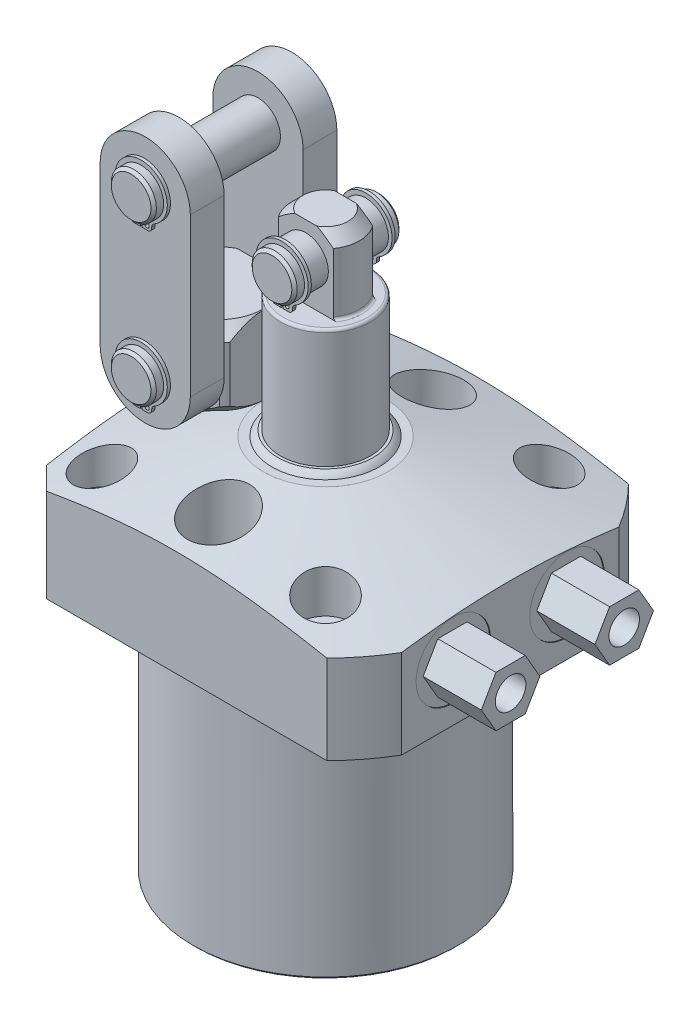
from build123d import *

# Parameters (mm, degrees)
SKETCH3_OUTSIDE_W          = 162.862
SKETCH3_OUTSIDE_H          = 162.862
SKETCH3_OUTSIDE_W_2        = 94.4626
SKETCH3_OUTSIDE_H_2        = 84.9376
CUT_EXTRUDE9_DEPTH         = 106.3498
CHAMFER8_SIZE              = 6.35
CHAMFER5_SIZE              = 0.762
HOLE1_D                    = 8.7376
HOLE1_DEPTH                = 36.4998
HOLE1_CBORE_D              = 14.2748
HOLE1_CBORE_DEPTH          = 17.4498
SKETCH34_R                 = 8.7503
CUT_EXTRUDE10_DEPTH        = 19.05
EXTRUDE14_DEPTH            = 16.383
HOLE2_D                    = 8.6106
HOLE2_DEPTH                = 6.7056
SKETCH33_R                 = 0.889
CUT_EXTRUDE7_DEPTH         = 20.6248
FILLET4_R                  = 0.762
SKETCH29_R                 = 6.3373
EXTRUDE11_DEPTH            = 15.0749
EXTRUDE2_START             = -2.8194
SKETCH16_R                 = 0.5969
EXTRUDE2_DEPTH             = 0.889
CHAMFER6_SIZE              = 0.762
CUT_EXTRUDE11_DEPTH        = 22.225
SKETCH30_R                 = 6.3373
EXTRUDE12_DEPTH            = 24.5999
EXTRUDE4_START             = -2.8194
SKETCH19_R                 = 0.5969
EXTRUDE4_DEPTH             = 0.889
EXTRUDE13_DEPTH            = 9.525
CHAMFER7_SIZE              = 0.762
LPATTERN2_COUNT            = 2
LPATTERN2_PITCH            = 44.45
LPATTERN2_START            = -2.8194
LPATTERN2_COPY_1_SKETCH_R  = 0.5969
LPATTERN2_COPY_1_DEPTH     = 0.889
CHAMFER7_OF_LPATTERN2_SIZE = 0.762


with BuildPart() as part:
    # Sketch28 → Revolve7 (revolve)
    with BuildSketch(Plane.XY, mode=Mode.PRIVATE) as revolve7_sk:
        Polygon((-17.4625, 36.4998), (-60.325, 25.014827739), (-60.325, 0), (-37.2999, 0), (-37.2999, -69.85), (0, -69.85), (0, 36.4998), align=None)
    revolve(revolve7_sk.sketch.rotate(Axis((0, 0, 0), (0, 1, 0)), 270), axis=Axis((0, 0, 0), (0, 1, 0)))  # turned: the seam where the file's is

    # Sketch3 outside → Cut-Extrude9 (cut)
    with BuildSketch(Plane(origin=(0, 36.4998, 0), x_dir=(-1, 0, 0), z_dir=(0, 1, 0))):
        Rectangle(SKETCH3_OUTSIDE_W, SKETCH3_OUTSIDE_H)
        with Locations((-4.7625, 0)):
            Rectangle(SKETCH3_OUTSIDE_W_2, SKETCH3_OUTSIDE_H_2, mode=Mode.SUBTRACT)
    extrude(amount=-CUT_EXTRUDE9_DEPTH, mode=Mode.SUBTRACT)

    # Chamfer8
    chamfer8_edges = [part.edges().sort_by_distance(p)[0] for p in [
        (-42.4688, 12.542923443, -42.4688),
        (-42.4688, 12.542923443, 42.4688),
    ]]
    chamfer(chamfer8_edges, length=CHAMFER8_SIZE)

    # Chamfer5
    chamfer5_edges = [part.edges().sort_by_distance(p)[0] for p in [
        (0, -69.85, 37.2999),
    ]]
    chamfer(chamfer5_edges, length=CHAMFER5_SIZE)

    # Hole1
    with Locations(Plane(origin=(0, 36.4998, 0), x_dir=(-1, 0, 0), z_dir=(0, 1, 0))):
        with Locations((-31.496, -31.496), (-31.496, 31.496), (31.496, -31.496), (31.496, 31.496)):
            CounterBoreHole(HOLE1_D / 2, HOLE1_CBORE_D / 2, HOLE1_CBORE_DEPTH, depth=HOLE1_DEPTH)

    # Sketch34 → Cut-Extrude10 (cut)
    with BuildSketch(Plane(origin=(0, 36.4998, 0), x_dir=(1, 0, 0), z_dir=(0, 1, 0))):
        with Locations(Location((0, 30.1498, 0), (0, 0, 270))):  # turned: the seam where the file's is
            Circle(SKETCH34_R)
        with Locations(Location((0, -30.1498, 0), (0, 0, 136.329694208))):  # turned: the seam where the file's is
            Circle(SKETCH34_R)
        with Locations(Location((-30.1498, 0, 0), (0, 0, 270))):  # turned: the seam where the file's is
            Circle(SKETCH34_R)
    extrude(amount=-CUT_EXTRUDE10_DEPTH, mode=Mode.SUBTRACT)

    # S2D0007 → Cut-Revolve2 (revolve, cut)
    with BuildSketch(Plane.XZ.offset(-15.875)):
        Polygon((51.9938, -16.002), (51.9938, -26.4795), (51.7398, -26.4795), (51.7398, -22.21865), (49.6697, -21.778636662), (48.871463338, -20.9804), (37.7698, -20.9804), (34.778475494, -16.002), align=None)
    cut_revolve2 = revolve(axis=Axis((-11.746808274, 15.875, -16.002), (-1, 0, 0)), mode=Mode.SUBTRACT)

    # Sketch6 → Cut-Revolve3 (revolve, cut)
    with BuildSketch(Plane.XY.offset(-16.002), mode=Mode.PRIVATE) as cut_revolve3_sk:
        with BuildLine():
            Line((50.67935, 0), (50.67935, 1.4478))
            Line((50.67935, 1.4478), (47.61885581, 1.4478))
            ThreePointArc((47.61885581, 1.4478), (46.937254622, 0.917608896), (46.1518, 0.5588))
            Line((46.1518, 0.5588), (45.0088, 0.5588))
            Line((45.0088, 0.5588), (45.0088, 0))
            Line((45.0088, 0), (50.67935, 0))
        make_face()
    cut_revolve3 = revolve(cut_revolve3_sk.sketch.rotate(Axis((45.0088, -21.049171587, -16.002), (0, 1, 0)), 90), axis=Axis((45.0088, -21.049171587, -16.002), (0, 1, 0)), mode=Mode.SUBTRACT)  # turned: the seam where the file's is

    # Sketch38 → Extrude14 (add)
    with BuildSketch(Plane(origin=(51.7398, 0, 0), x_dir=(0, 0, -1), z_dir=(1, 0, 0))):
        Polygon((24.243559623, 15.875), (20.122779811, 23.0124), (11.881220189, 23.0124), (7.760440377, 15.875), (11.881220189, 8.7376), (20.122779811, 8.7376), align=None)
    extrude14 = extrude(amount=EXTRUDE14_DEPTH)

    # Hole2
    with Locations(Plane(origin=(68.1228, 0, 0), x_dir=(0, 0, -1), z_dir=(1, 0, 0))):
        with Locations((16.002, 15.875)):
            hole2 = Hole(HOLE2_D / 2, depth=HOLE2_DEPTH)

    # Mirror6: Cut-Revolve2, Cut-Revolve3, Extrude14, Hole2 across plane
    add(cut_revolve2.mirror(Plane.XY), mode=Mode.SUBTRACT)
    add(cut_revolve3.mirror(Plane.XY), mode=Mode.SUBTRACT)
    add(extrude14.mirror(Plane.XY))
    add(hole2.mirror(Plane.XY), mode=Mode.SUBTRACT)

    # Sketch12 → Revolve2 (revolve)
    with BuildSketch(Plane(origin=(0, 0, 0), x_dir=(-1, 0, 0), z_dir=(0, 0, -1)), mode=Mode.PRIVATE) as revolve2_sk:
        with BuildLine():
            Line((0, 36.4998), (0, 38.0238))
            Line((0, 38.0238), (13.462, 38.0238))
            ThreePointArc((13.462, 38.0238), (14.358696206, 37.357310568), (15.0749, 36.4998))
            Line((15.0749, 36.4998), (0, 36.4998))
        make_face()
    revolve(revolve2_sk.sketch.rotate(Axis((0, 22.10562, 0), (0, 1, 0)), 270), axis=Axis((0, 22.10562, 0), (0, 1, 0)))  # turned: the seam where the file's is

    # Sketch13 → Revolve3 (revolve)
    with BuildSketch(Plane.XY, mode=Mode.PRIVATE) as revolve3_sk:
        Polygon((0, 38.0238), (0, 92.075), (6.35, 92.075), (9.525, 88.9), (9.525, 71.4502), (12.69365, 71.4502), (12.69365, 38.0238), align=None)
    revolve(revolve3_sk.sketch.rotate(Axis((0, 23.02637, 0), (0, 1, 0)), 90), axis=Axis((0, 23.02637, 0), (0, 1, 0)))  # turned: the seam where the file's is

    # Sketch14 → Cut-Extrude7 (cut)
    with BuildSketch(Plane(origin=(0, 92.075, 0), x_dir=(-1, 0, 0), z_dir=(0, 1, 0))):
        with BuildLine():
            Line((-7.741074537, 5.5499), (7.741074537, 5.5499))
            ThreePointArc((7.741074537, 5.5499), (0, 9.525), (-7.741074537, 5.5499))
        make_face()
        with BuildLine():
            Line((7.741074537, -5.5499), (-7.741074537, -5.5499))
            ThreePointArc((-7.741074537, -5.5499), (0, -9.525), (7.741074537, -5.5499))
        make_face()
    extrude(amount=-CUT_EXTRUDE7_DEPTH, mode=Mode.SUBTRACT)

    # Fillet4
    fillet4_edges = [part.edges().sort_by_distance(p)[0] for p in [
        (0, 71.4502, 12.69365),
        (-9.525, 71.4502, 0),
        (9.525, 71.4502, 0),
    ]]
    fillet(fillet4_edges, radius=FILLET4_R)

    # Sketch29 → Extrude11 (add, symmetric)
    with BuildSketch(Plane.XY):
        with Locations((0, 82.55)):
            Circle(SKETCH29_R)
    extrude(amount=EXTRUDE11_DEPTH, both=True)

    # Sketch16 → Extrude2 (add)
    with BuildSketch(Plane(origin=(0, 52.3748, 15.0749), x_dir=(1, 0, 0), z_dir=(0, 0, 1)).offset(EXTRUDE2_START)):
        with BuildLine():
            Line((0.23876, 24.236397543), (0.23876, 21.493197543))
            Line((0.23876, 21.493197543), (1.78816, 21.493197543))
            ThreePointArc((1.78816, 21.493197543), (2.632304075, 21.842853468), (2.98196, 22.686997543))
            Line((2.98196, 22.686997543), (2.98196, 22.931638033))
            ThreePointArc((2.98196, 22.931638033), (3.14610012, 23.535756375), (3.593383976, 23.973749643))
            ThreePointArc((3.593383976, 23.973749643), (0, 37.7698), (-3.593383976, 23.973749643))
            ThreePointArc((-3.593383976, 23.973749643), (-3.14610012, 23.535756375), (-2.98196, 22.931638033))
            Line((-2.98196, 22.931638033), (-2.98196, 22.686997543))
            ThreePointArc((-2.98196, 22.686997543), (-2.632304075, 21.842853468), (-1.78816, 21.493197543))
            Line((-1.78816, 21.493197543), (-0.23876, 21.493197543))
            Line((-0.23876, 21.493197543), (-0.23876, 24.236397543))
            ThreePointArc((-0.23876, 24.236397543), (0, 36.1188), (0.23876, 24.236397543))
        make_face()
        with Locations((1.43256, 22.686997543)):
            Circle(SKETCH16_R, mode=Mode.SUBTRACT)
        with Locations(Location((-1.43256, 22.686997543, 0), (0, 0, 180))):  # turned: the seam where the file's is
            Circle(SKETCH16_R, mode=Mode.SUBTRACT)
    extrude2 = extrude(amount=-EXTRUDE2_DEPTH)

    # Chamfer6
    chamfer6_edges = [part.edges().sort_by_distance(p)[0] for p in [
        (-6.3373, 82.55, -15.0749),
        (-6.3373, 82.55, 15.0749),
    ]]
    chamfer(chamfer6_edges, length=CHAMFER6_SIZE)

    # Mirror2: Extrude2 across plane
    add(extrude2.mirror(Plane.XY))

    # Sketch35 → Revolve10 (revolve)
    with BuildSketch(Plane.XY, mode=Mode.PRIVATE) as revolve10_sk:
        Polygon((-30.1498, 17.4498), (-20.6248, 17.4498), (-20.6248, 36.4998), (-17.5768, 36.4998), (-14.2748, 39.8018), (-14.2748, 55.4228), (-17.5768, 58.7248), (-30.1498, 58.7248), align=None)
    revolve(revolve10_sk.sketch.rotate(Axis((-30.1498, 43.57409058, 0), (0, -1, 0)), 180), axis=Axis((-30.1498, 43.57409058, 0), (0, -1, 0)))  # turned: the seam where the file's is

    # Sketch36 → Cut-Extrude11 (cut)
    with BuildSketch(Plane(origin=(0, 58.7248, 0), x_dir=(1, 0, 0), z_dir=(0, 1, 0))):
        with BuildLine():
            Line((-41.48681763, 11.1125), (-18.81278237, 11.1125))
            ThreePointArc((-18.81278237, 11.1125), (-30.1498, 15.875), (-41.48681763, 11.1125))
        make_face()
        with BuildLine():
            Line((-42.8498, 9.525), (-42.8498, -9.525))
            ThreePointArc((-42.8498, -9.525), (-46.0248, 0), (-42.8498, 9.525))
        make_face()
        with BuildLine():
            Line((-41.48681763, -11.1125), (-18.81278237, -11.1125))
            ThreePointArc((-18.81278237, -11.1125), (-30.1498, -15.875), (-41.48681763, -11.1125))
        make_face()
        with BuildLine():
            Line((-17.4498, 9.525), (-17.4498, -9.525))
            ThreePointArc((-17.4498, -9.525), (-14.2748, 0), (-17.4498, 9.525))
        make_face()
    extrude(amount=-CUT_EXTRUDE11_DEPTH, mode=Mode.SUBTRACT)

    # Sketch30 → Extrude12 (add, symmetric)
    with BuildSketch(Plane.XY):
        with Locations((-30.1498, 47.625)):
            Circle(SKETCH30_R)
    extrude12 = extrude(amount=EXTRUDE12_DEPTH, both=True)

    # Sketch19 → Extrude4 (add)
    with BuildSketch(Plane(origin=(-22.225, 11.0998, 24.5999), x_dir=(1, 0, 0), z_dir=(0, 0, 1)).offset(EXTRUDE4_START)):
        with BuildLine():
            Line((-7.68604, 30.586397543), (-7.68604, 27.843197543))
            Line((-7.68604, 27.843197543), (-6.13664, 27.843197543))
            ThreePointArc((-6.13664, 27.843197543), (-5.292495925, 28.192853468), (-4.94284, 29.036997543))
            Line((-4.94284, 29.036997543), (-4.94284, 29.281638033))
            ThreePointArc((-4.94284, 29.281638033), (-4.77869988, 29.885756375), (-4.331416024, 30.323749643))
            ThreePointArc((-4.331416024, 30.323749643), (-7.9248, 44.1198), (-11.518183976, 30.323749643))
            ThreePointArc((-11.518183976, 30.323749643), (-11.07090012, 29.885756375), (-10.90676, 29.281638033))
            Line((-10.90676, 29.281638033), (-10.90676, 29.036997543))
            ThreePointArc((-10.90676, 29.036997543), (-10.557104075, 28.192853468), (-9.71296, 27.843197543))
            Line((-9.71296, 27.843197543), (-8.16356, 27.843197543))
            Line((-8.16356, 27.843197543), (-8.16356, 30.586397543))
            ThreePointArc((-8.16356, 30.586397543), (-7.9248, 42.4688), (-7.68604, 30.586397543))
        make_face()
        with Locations((-6.25348, 29.036997543)):
            Circle(SKETCH19_R, mode=Mode.SUBTRACT)
        with Locations(Location((-9.59612, 29.036997543, 0), (0, 0, 180))):  # turned: the seam where the file's is
            Circle(SKETCH19_R, mode=Mode.SUBTRACT)
    extrude4 = extrude(amount=-EXTRUDE4_DEPTH)

    # Sketch37 → Extrude13 (add)
    with BuildSketch(Plane.XY.offset(11.1125)):
        with BuildLine():
            Line((-42.849800117, 92.074999966), (-42.8498, 47.624999966))
            ThreePointArc((-42.8498, 47.624999966), (-30.149799966, 34.925), (-17.4498, 47.625000034))
            Line((-17.4498, 47.625000034), (-17.449800117, 92.075000034))
            ThreePointArc((-17.449800117, 92.075000034), (-30.149800151, 104.775), (-42.849800117, 92.074999966))
        make_face()
    extrude13 = extrude(amount=EXTRUDE13_DEPTH)

    # Mirror3: Extrude4 across plane
    add(extrude4.mirror(Plane.XY))

    # Chamfer7
    chamfer7_edges = [part.edges().sort_by_distance(p)[0] for p in [
        (-36.4871, 47.625, -24.5999),
        (-36.4871, 47.625, 24.5999),
    ]]
    chamfer(chamfer7_edges, length=CHAMFER7_SIZE)

    # LPattern2: Extrude4, Extrude12 ×2
    with Locations(*[(0, i * LPATTERN2_PITCH, 0) for i in range(1, LPATTERN2_COUNT)]):
        add(extrude4)
        add(extrude12)

    # LPattern2 copy 1 sketch → LPattern2 copy 1 (add)
    with BuildSketch(Plane(origin=(-22.225000117, 55.5498, -24.5999), x_dir=(1, 0, 0), z_dir=(0, 0, -1)).offset(LPATTERN2_START)):
        with BuildLine():
            Line((-7.68604, -30.586397543), (-7.68604, -27.843197543))
            Line((-7.68604, -27.843197543), (-6.13664, -27.843197543))
            ThreePointArc((-6.13664, -27.843197543), (-5.292495925, -28.192853468), (-4.94284, -29.036997543))
            Line((-4.94284, -29.036997543), (-4.94284, -29.281638033))
            ThreePointArc((-4.94284, -29.281638033), (-4.77869988, -29.885756375), (-4.331416024, -30.323749643))
            ThreePointArc((-4.331416024, -30.323749643), (-7.9248, -44.1198), (-11.518183976, -30.323749643))
            ThreePointArc((-11.518183976, -30.323749643), (-11.07090012, -29.885756375), (-10.90676, -29.281638033))
            Line((-10.90676, -29.281638033), (-10.90676, -29.036997543))
            ThreePointArc((-10.90676, -29.036997543), (-10.557104075, -28.192853468), (-9.71296, -27.843197543))
            Line((-9.71296, -27.843197543), (-8.16356, -27.843197543))
            Line((-8.16356, -27.843197543), (-8.16356, -30.586397543))
            ThreePointArc((-8.16356, -30.586397543), (-7.9248, -42.4688), (-7.68604, -30.586397543))
        make_face()
        with Locations((-6.25348, -29.036997543)):
            Circle(LPATTERN2_COPY_1_SKETCH_R, mode=Mode.SUBTRACT)
        with Locations((-9.59612, -29.036997543)):
            Circle(LPATTERN2_COPY_1_SKETCH_R, mode=Mode.SUBTRACT)
    extrude(amount=-LPATTERN2_COPY_1_DEPTH)

    # Chamfer7 of LPattern2
    chamfer7_of_lpattern2_edges = [part.edges().sort_by_distance(p)[0] for p in [
        (-36.487100117, 92.075, -24.5999),
        (-36.487100117, 92.075, 24.5999),
    ]]
    chamfer(chamfer7_of_lpattern2_edges, length=CHAMFER7_OF_LPATTERN2_SIZE)

    # Mirror8: Extrude13 across plane
    add(extrude13.mirror(Plane.XY))


with BuildPart() as body_2:
    # Sketch33 → Revolve9 (revolve)
    with BuildSketch(Plane.XY.offset(-16.002), mode=Mode.PRIVATE) as revolve9_sk:
        with Locations((40.22725, 0.5842)):
            Circle(SKETCH33_R)
    revolve(revolve9_sk.sketch.rotate(Axis((45.0088, 8.329668034, -16.002), (0, -1, 0)), 90), axis=Axis((45.0088, 8.329668034, -16.002), (0, -1, 0)))  # turned: the seam where the file's is


with BuildPart() as body_3:
    # Mirror7: mirrored copy
    add(body_2.part.mirror(Plane.XY))


solid = Compound([part.part, body_2.part, body_3.part])
